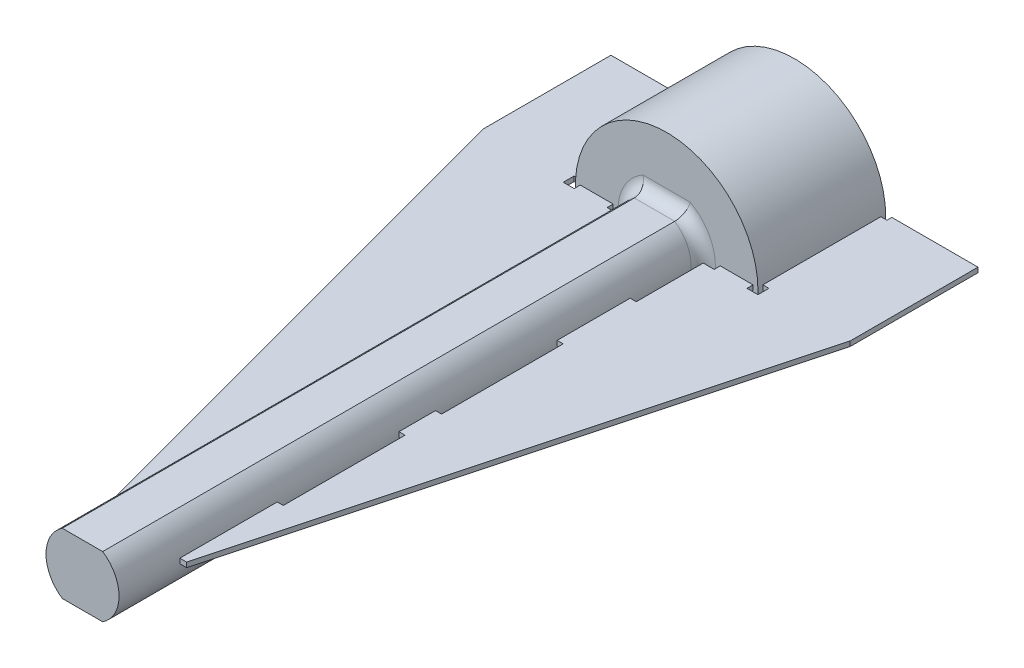
from build123d import *

# Parameters (mm, degrees)
SKETCH2_R                = 7.5
BOSS_EXTRUDE1_DEPTH      = 4
BOSS_EXTRUDE1_DEPTH_BACK = 5.5
SKETCH4_R                = 7.5
BOSS_EXTRUDE2_DEPTH      = 1
BOSS_EXTRUDE3_DEPTH      = 48
FILLET1_R                = 1
BOSS_EXTRUDE6_DEPTH      = 0.2
BOSS_EXTRUDE6_2_DEPTH    = 0.2


with BuildPart() as part:
    # Sketch2 → Boss-Extrude1 (new, two sides)
    with BuildSketch(Plane.XY) as boss_extrude1_sk:
        with Locations((-178.577921964, 19.246491703)):
            Circle(SKETCH2_R)
        with BuildLine():
            ThreePointArc((-181.558337123, 16.709622023), (-181.558678585, 16.708789517), (-181.559019214, 16.70795667))
            ThreePointArc((-181.559019214, 16.70795667), (-181.726852484, 16.105372267), (-181.751518169, 15.480338211))
            ThreePointArc((-181.751518169, 15.480338211), (-181.374286139, 15.192361414), (-180.971087428, 14.942030754))
            ThreePointArc((-180.971087428, 14.942030754), (-180.395580689, 15.187118416), (-179.891916803, 15.558061347))
            ThreePointArc((-179.891916803, 15.558061347), (-179.891259277, 15.558675612), (-179.890602365, 15.559290534))
            ThreePointArc((-179.890602365, 15.559290534), (-179.890481827, 15.558398832), (-179.890360397, 15.557507251))
            ThreePointArc((-179.890360397, 15.557507251), (-179.734416071, 14.951737216), (-179.443260152, 14.398109002))
            ThreePointArc((-179.443260152, 14.398109002), (-178.972579233, 14.337329795), (-178.498233577, 14.322136439))
            ThreePointArc((-178.498233577, 14.322136439), (-178.122373952, 14.82214195), (-177.871659697, 15.395219895))
            ThreePointArc((-177.871659697, 15.395219895), (-177.871397395, 15.396080627), (-177.871135954, 15.396941621))
            ThreePointArc((-177.871135954, 15.396941621), (-177.870585714, 15.396229653), (-177.870034762, 15.395518236))
            ThreePointArc((-177.870034762, 15.395518236), (-177.432097996, 14.94887816), (-176.903135467, 14.615000022))
            ThreePointArc((-176.903135467, 14.615000022), (-176.465124231, 14.797704144), (-176.046732165, 15.021719141))
            ThreePointArc((-176.046732165, 15.021719141), (-175.971230936, 15.642666427), (-176.040644995, 16.264323613))
            ThreePointArc((-176.040644995, 16.264323613), (-176.040848201, 16.26520018), (-176.041052283, 16.266076544))
            ThreePointArc((-176.041052283, 16.266076544), (-176.040219777, 16.265735082), (-176.039386931, 16.265394452))
            ThreePointArc((-176.039386931, 16.265394452), (-175.436802528, 16.097561183), (-174.811768471, 16.072895498))
            ThreePointArc((-174.811768471, 16.072895498), (-174.523791675, 16.450127528), (-174.273461015, 16.853326238))
            ThreePointArc((-174.273461015, 16.853326238), (-174.518548677, 17.428832977), (-174.889491607, 17.932496864))
            ThreePointArc((-174.889491607, 17.932496864), (-174.890105873, 17.93315439), (-174.890720795, 17.933811301))
            ThreePointArc((-174.890720795, 17.933811301), (-174.889829093, 17.93393184), (-174.888937511, 17.934053269))
            ThreePointArc((-174.888937511, 17.934053269), (-174.283167476, 18.089997596), (-173.729539262, 18.381153514))
            ThreePointArc((-173.729539262, 18.381153514), (-173.668760056, 18.851834433), (-173.6535667, 19.326180089))
            ThreePointArc((-173.6535667, 19.326180089), (-174.153572211, 19.702039715), (-174.726650155, 19.95275397))
            ThreePointArc((-174.726650155, 19.95275397), (-174.727510888, 19.953016271), (-174.728371882, 19.953277712))
            ThreePointArc((-174.728371882, 19.953277712), (-174.727659914, 19.953827953), (-174.726948497, 19.954378905))
            ThreePointArc((-174.726948497, 19.954378905), (-174.280308421, 20.39231567), (-173.946430283, 20.921278199))
            ThreePointArc((-173.946430283, 20.921278199), (-174.129134405, 21.359289436), (-174.353149401, 21.777681502))
            ThreePointArc((-174.353149401, 21.777681502), (-174.974096688, 21.85318273), (-175.595753874, 21.783768672))
            ThreePointArc((-175.595753874, 21.783768672), (-175.596630441, 21.783565466), (-175.597506804, 21.783361383))
            ThreePointArc((-175.597506804, 21.783361383), (-175.597165342, 21.784193889), (-175.596824713, 21.785026736))
            ThreePointArc((-175.596824713, 21.785026736), (-175.428991444, 22.387611138), (-175.404325759, 23.012645195))
            ThreePointArc((-175.404325759, 23.012645195), (-175.781557788, 23.300621992), (-176.184756499, 23.550952652))
            ThreePointArc((-176.184756499, 23.550952652), (-176.760263238, 23.30586499), (-177.263927124, 22.934922059))
            ThreePointArc((-177.263927124, 22.934922059), (-177.26458465, 22.934307794), (-177.265241562, 22.933692872))
            ThreePointArc((-177.265241562, 22.933692872), (-177.2653621, 22.934584574), (-177.26548353, 22.935476155))
            ThreePointArc((-177.26548353, 22.935476155), (-177.421427856, 23.54124619), (-177.712583775, 24.094874404))
            ThreePointArc((-177.712583775, 24.094874404), (-178.183264694, 24.155653611), (-178.65761035, 24.170846966))
            ThreePointArc((-178.65761035, 24.170846966), (-179.033469975, 23.670841456), (-179.28418423, 23.097763511))
            ThreePointArc((-179.28418423, 23.097763511), (-179.284446532, 23.096902779), (-179.284707973, 23.096041785))
            ThreePointArc((-179.284707973, 23.096041785), (-179.285258213, 23.096753752), (-179.285809165, 23.097465169))
            ThreePointArc((-179.285809165, 23.097465169), (-179.723745931, 23.544105246), (-180.25270846, 23.877983384))
            ThreePointArc((-180.25270846, 23.877983384), (-180.690719696, 23.695279261), (-181.109111762, 23.471264265))
            ThreePointArc((-181.109111762, 23.471264265), (-181.184612991, 22.850316978), (-181.115198932, 22.228659792))
            ThreePointArc((-181.115198932, 22.228659792), (-181.114995726, 22.227783225), (-181.114791644, 22.226906862))
            ThreePointArc((-181.114791644, 22.226906862), (-181.11562415, 22.227248324), (-181.116456997, 22.227588953))
            ThreePointArc((-181.116456997, 22.227588953), (-181.719041399, 22.395422223), (-182.344075456, 22.420087908))
            ThreePointArc((-182.344075456, 22.420087908), (-182.632052252, 22.042855878), (-182.882382912, 21.639657168))
            ThreePointArc((-182.882382912, 21.639657168), (-182.637295251, 21.064150429), (-182.26635232, 20.560486542))
            ThreePointArc((-182.26635232, 20.560486542), (-182.265738055, 20.559829016), (-182.265123132, 20.559172105))
            ThreePointArc((-182.265123132, 20.559172105), (-182.266014835, 20.559051566), (-182.266906416, 20.558930136))
            ThreePointArc((-182.266906416, 20.558930136), (-182.872676451, 20.40298581), (-183.426304665, 20.111829892))
            ThreePointArc((-183.426304665, 20.111829892), (-183.487083872, 19.641148972), (-183.502277227, 19.166803316))
            ThreePointArc((-183.502277227, 19.166803316), (-183.002271717, 18.790943691), (-182.429193772, 18.540229436))
            ThreePointArc((-182.429193772, 18.540229436), (-182.42833304, 18.539967134), (-182.427472045, 18.539705693))
            ThreePointArc((-182.427472045, 18.539705693), (-182.428184013, 18.539155453), (-182.42889543, 18.538604501))
            ThreePointArc((-182.42889543, 18.538604501), (-182.875535506, 18.100667735), (-183.209413645, 17.571705206))
            ThreePointArc((-183.209413645, 17.571705206), (-183.026709522, 17.13369397), (-182.802694526, 16.715301904))
            ThreePointArc((-182.802694526, 16.715301904), (-182.181747239, 16.639800676), (-181.560090053, 16.709214734))
            ThreePointArc((-181.560090053, 16.709214734), (-181.559213486, 16.70941794), (-181.558337123, 16.709622023))
        make_face(mode=Mode.SUBTRACT)
    extrude(amount=BOSS_EXTRUDE1_DEPTH)
    extrude(boss_extrude1_sk.sketch, amount=-BOSS_EXTRUDE1_DEPTH_BACK)

    # Sketch4 → Boss-Extrude2 (add)
    with BuildSketch(Plane.XY.offset(4)):
        with Locations((-178.577921964, 19.246491703)):
            Circle(SKETCH4_R)
    extrude(amount=BOSS_EXTRUDE2_DEPTH)

    # Sketch6 → Boss-Extrude3 (add)
    with BuildSketch(Plane.XY.offset(5)):
        with BuildLine():
            Line((-180.236234359, 21.746491703), (-176.919609568, 21.746491703))
            ThreePointArc((-176.919609568, 21.746491703), (-175.577921964, 19.246491703), (-176.919609568, 16.746491703))
            Line((-176.919609568, 16.746491703), (-180.236234359, 16.746491703))
            ThreePointArc((-180.236234359, 16.746491703), (-181.577921964, 19.246491703), (-180.236234359, 21.746491703))
        make_face()
    extrude(amount=BOSS_EXTRUDE3_DEPTH)

    # Fillet1
    fillet1_edges = [part.edges().sort_by_distance(p)[0] for p in [
        (-175.577921964, 19.246491703, 5),
        (-178.577921964, 21.746491703, 5),
        (-181.577921964, 19.246491703, 5),
        (-178.577921964, 16.746491703, 5),
    ]]
    fillet(fillet1_edges, radius=FILLET1_R)


with BuildPart() as body_2:
    # Sketch7 → Boss-Extrude6 (new, symmetric)
    with BuildSketch(Plane(origin=(0, 19.246491703, 0), x_dir=(1, 0, 0), z_dir=(0, 1, 0))):
        Polygon((-182.077921964, -5.5), (-182.077921964, -11), (-181.577921964, -11), (-181.577921964, -17), (-182.077921964, -17), (-182.077921964, -27), (-181.577921964, -27), (-181.577921964, -30), (-182.077921964, -30), (-182.077921964, -40), (-181.577921964, -40), (-181.577921964, -48), (-182.135795076, -48), (-193.65761035, -5), (-193.65761035, 5.5), (-186.577921964, 5.5), (-186.577921964, 5.1), (-186.077921964, 5.1), (-186.077921964, -4.6), (-186.577921964, -4.6), (-186.577921964, -5.5), (-185.677921964, -5.5), (-185.677921964, -5), (-182.977921964, -5), (-182.977921964, -5.5), align=None)
    extrude(amount=BOSS_EXTRUDE6_DEPTH, both=True)


with BuildPart() as body_3:
    # Sketch7 → Boss-Extrude6 2 (new, symmetric)
    with BuildSketch(Plane(origin=(0, 19.246491703, 0), x_dir=(1, 0, 0), z_dir=(0, 1, 0))):
        Polygon((-175.020048852, -48), (-175.577921964, -48), (-175.577921964, -40), (-175.077921964, -40), (-175.077921964, -30), (-175.577921964, -30), (-175.577921964, -27), (-175.077921964, -27), (-175.077921964, -17), (-175.577921964, -17), (-175.577921964, -11), (-175.077921964, -11), (-175.077921964, -5.5), (-174.177921964, -5.5), (-174.177921964, -5), (-171.477921964, -5), (-171.477921964, -5.5), (-170.577921964, -5.5), (-170.577921964, -4.6), (-171.077921964, -4.6), (-171.077921964, 5.1), (-170.577921964, 5.1), (-170.577921964, 5.5), (-163.498233577, 5.5), (-163.498233577, -5), align=None)
    extrude(amount=BOSS_EXTRUDE6_2_DEPTH, both=True)


solid = Compound([part.part, body_2.part, body_3.part])
